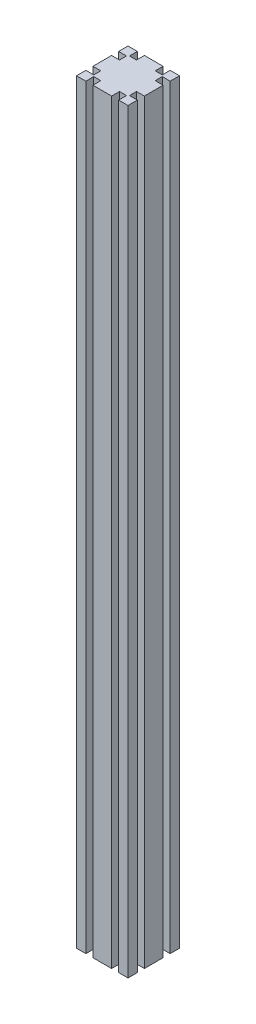
from build123d import *

# Parameters (mm, degrees)
EXTRUDE_1_DEPTH = 880


with BuildPart() as part:
    # 草图1 → 凸台-拉伸1 (new body)
    with BuildSketch(Plane(origin=(0, 0, 0), x_dir=(1, 0, 0), z_dir=(0, 1, 0))):
        Polygon((10.9, 60), (0, 60), (0, 49.1), (9.2, 49.1), (9.2, 40.9), (0, 40.9), (0, 30), (30, 30), (30, 60), (19.1, 60), (19.1, 50.8), (10.9, 50.8), align=None)
        Polygon((30, 30), (0, 30), (0, 19.1), (9.2, 19.1), (9.2, 10.9), (0, 10.9), (0, 0), (10.9, 0), (10.9, 9.2), (19.1, 9.2), (19.1, 0), (40.9, 0), (40.9, 9.2), (49.1, 9.2), (49.1, 0), (60, 0), (60, 10.9), (50.8, 10.9), (50.8, 19.1), (60, 19.1), (60, 40.9), (50.8, 40.9), (50.8, 49.1), (60, 49.1), (60, 60), (49.1, 60), (49.1, 50.8), (40.9, 50.8), (40.9, 60), (30, 60), align=None)
    extrude(amount=EXTRUDE_1_DEPTH)


solid = part.part
